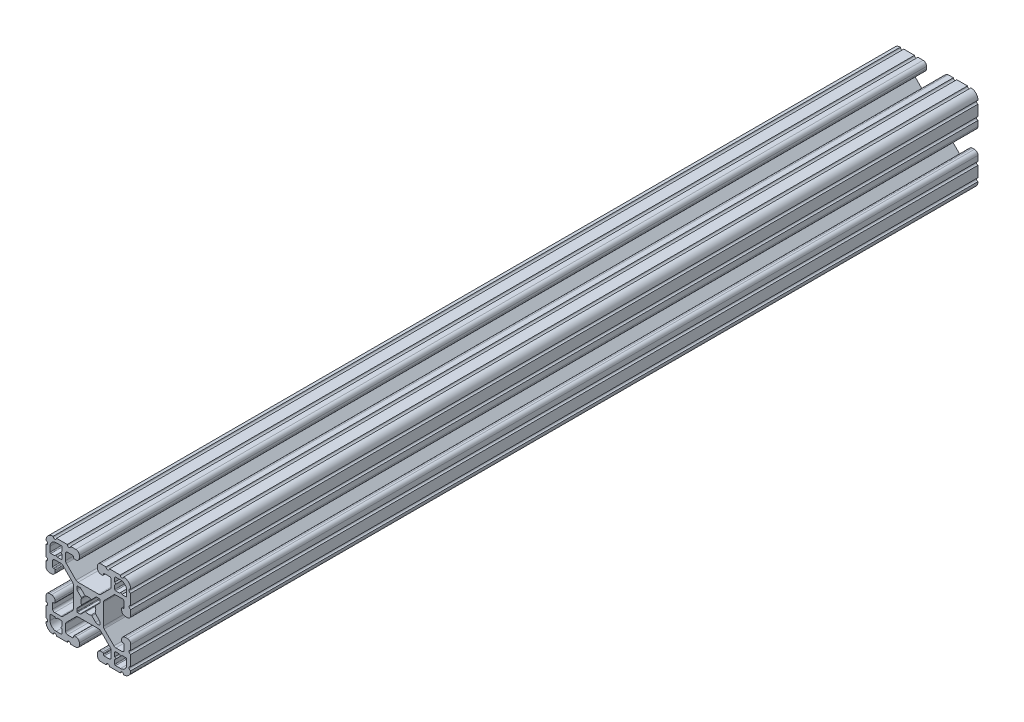
from build123d import *

# Parameters (mm, degrees)
BOSS_EXTRUDE1_DEPTH = 381


with BuildPart() as part:
    # Sketch1 → Boss-Extrude1 (new body)
    with BuildSketch(Plane(origin=(0, 0, -2322.576), x_dir=(-1, 0, 0), z_dir=(0, 0, -1))):
        with BuildLine():
            Line((19.05, -14.325600033), (19.05, -9.4996))
            ThreePointArc((19.05, -9.4996), (18.288, -8.7376), (19.05, -7.9756))
            Line((19.05, -7.9756), (19.05, -5.6388))
            ThreePointArc((19.05, -5.6388), (18.588751759, -4.525248241), (17.4752, -4.064))
            Line((17.4752, -4.064), (16.5608, -4.064))
            ThreePointArc((16.5608, -4.064), (15.447248241, -4.525248241), (14.986, -5.6388))
            Line((14.986, -5.6388), (14.986, -6.350014224))
            ThreePointArc((14.986, -6.350014224), (15.097592316, -6.619421908), (15.367, -6.731014224))
            Line((15.367, -6.731014224), (15.6972, -6.731014224))
            ThreePointArc((15.6972, -6.731014224), (15.966607684, -6.84260654), (16.0782, -7.112014224))
            Line((16.0782, -7.112014224), (16.0782, -9.398014224))
            ThreePointArc((16.0782, -9.398014224), (15.817817928, -10.026632152), (15.1892, -10.287014224))
            Line((15.1892, -10.287014224), (12.375630013, -10.287014224))
            ThreePointArc((12.375630013, -10.287014224), (11.889622054, -10.19034123), (11.477604401, -9.915039836))
            Line((11.477604401, -9.915039836), (7.115699788, -5.553135223))
            ThreePointArc((7.115699788, -5.553135223), (6.840398394, -5.14111757), (6.7437254, -4.655109611))
            Line((6.7437254, -4.655109611), (6.7437254, 4.655109611))
            ThreePointArc((6.7437254, 4.655109611), (6.840398394, 5.14111757), (7.115699788, 5.553135223))
            Line((7.115699788, 5.553135223), (11.477604401, 9.915039836))
            ThreePointArc((11.477604401, 9.915039836), (11.889622054, 10.19034123), (12.375630013, 10.287014224))
            Line((12.375630013, 10.287014224), (15.1892, 10.287014224))
            ThreePointArc((15.1892, 10.287014224), (15.817817928, 10.026632152), (16.0782, 9.398014224))
            Line((16.0782, 9.398014224), (16.0782, 7.112014224))
            ThreePointArc((16.0782, 7.112014224), (15.966607684, 6.84260654), (15.6972, 6.731014224))
            Line((15.6972, 6.731014224), (15.367, 6.731014224))
            ThreePointArc((15.367, 6.731014224), (15.097592316, 6.619421908), (14.986, 6.350014224))
            Line((14.986, 6.350014224), (14.986, 5.6388))
            ThreePointArc((14.986, 5.6388), (15.447248241, 4.525248241), (16.5608, 4.064))
            Line((16.5608, 4.064), (17.4752, 4.064))
            ThreePointArc((17.4752, 4.064), (18.588751759, 4.525248241), (19.05, 5.6388))
            Line((19.05, 5.6388), (19.05, 7.9756))
            ThreePointArc((19.05, 7.9756), (18.288, 8.7376), (19.05, 9.4996))
            Line((19.05, 9.4996), (19.05, 14.325599984))
            ThreePointArc((19.05, 14.325599984), (18.287999986, 15.087549208), (19.049898416, 15.849600009))
            ThreePointArc((19.049898416, 15.849600009), (18.120064036, 18.120064058), (15.849599977, 19.049898414))
            ThreePointArc((15.849599977, 19.049898414), (15.0875492, 18.288000035), (14.325600017, 19.050000016))
            Line((14.325600017, 19.050000016), (9.499600001, 19.050000016))
            ThreePointArc((9.499600001, 19.050000016), (8.737600001, 18.288000016), (7.975600001, 19.050000016))
            Line((7.975600001, 19.050000016), (5.638800016, 19.050000016))
            ThreePointArc((5.638800016, 19.050000016), (4.525248257, 18.588751775), (4.064000016, 17.475200016))
            Line((4.064000016, 17.475200016), (4.064000016, 16.5608))
            ThreePointArc((4.064000016, 16.5608), (4.525248257, 15.447248241), (5.638800016, 14.986))
            Line((5.638800016, 14.986), (6.350014224, 14.986))
            ThreePointArc((6.350014224, 14.986), (6.619421908, 15.097592316), (6.731014224, 15.367))
            Line((6.731014224, 15.367), (6.731014224, 15.6972))
            ThreePointArc((6.731014224, 15.6972), (6.84260654, 15.966607684), (7.112014224, 16.0782))
            Line((7.112014224, 16.0782), (9.398014224, 16.0782))
            ThreePointArc((9.398014224, 16.0782), (10.026632152, 15.817817928), (10.287014224, 15.1892))
            Line((10.287014224, 15.1892), (10.287014224, 12.375630013))
            ThreePointArc((10.287014224, 12.375630013), (10.19034123, 11.889622054), (9.915039836, 11.477604401))
            Line((9.915039836, 11.477604401), (5.553135223, 7.115699788))
            ThreePointArc((5.553135223, 7.115699788), (5.14111757, 6.840398394), (4.655109611, 6.7437254))
            Line((4.655109611, 6.7437254), (-4.655109611, 6.7437254))
            ThreePointArc((-4.655109611, 6.7437254), (-5.14111757, 6.840398394), (-5.553135223, 7.115699788))
            Line((-5.553135223, 7.115699788), (-9.915039836, 11.477604401))
            ThreePointArc((-9.915039836, 11.477604401), (-10.19034123, 11.889622054), (-10.287014224, 12.375630013))
            Line((-10.287014224, 12.375630013), (-10.287014224, 15.1892))
            ThreePointArc((-10.287014224, 15.1892), (-10.026632152, 15.817817928), (-9.398014224, 16.0782))
            Line((-9.398014224, 16.0782), (-7.112014224, 16.0782))
            ThreePointArc((-7.112014224, 16.0782), (-6.84260654, 15.966607684), (-6.731014224, 15.6972))
            Line((-6.731014224, 15.6972), (-6.731014224, 15.367))
            ThreePointArc((-6.731014224, 15.367), (-6.619421908, 15.097592316), (-6.350014224, 14.986))
            Line((-6.350014224, 14.986), (-5.638799984, 14.986))
            ThreePointArc((-5.638799984, 14.986), (-4.525248225, 15.447248241), (-4.063999984, 16.5608))
            Line((-4.063999984, 16.5608), (-4.063999984, 17.475200016))
            ThreePointArc((-4.063999984, 17.475200016), (-4.525248225, 18.588751775), (-5.638799984, 19.050000016))
            Line((-5.638799984, 19.050000016), (-7.975599999, 19.050000016))
            ThreePointArc((-7.975599999, 19.050000016), (-8.737599999, 18.288000016), (-9.499599999, 19.050000016))
            Line((-9.499599999, 19.050000016), (-14.325599999, 19.050000016))
            ThreePointArc((-14.325599999, 19.050000016), (-15.087549199, 18.288000018), (-15.849599993, 19.049898416))
            ThreePointArc((-15.849599993, 19.049898416), (-18.120064042, 18.120064036), (-19.049898398, 15.849599976))
            ThreePointArc((-19.049898398, 15.849599976), (-18.288000019, 15.087549199), (-19.05, 14.325600017))
            Line((-19.05, 14.325600017), (-19.05, 9.4996))
            ThreePointArc((-19.05, 9.4996), (-18.288, 8.7376), (-19.05, 7.9756))
            Line((-19.05, 7.9756), (-19.05, 5.6388))
            ThreePointArc((-19.05, 5.6388), (-18.588751759, 4.525248241), (-17.4752, 4.064))
            Line((-17.4752, 4.064), (-16.5608, 4.064))
            ThreePointArc((-16.5608, 4.064), (-15.447248241, 4.525248241), (-14.986, 5.6388))
            Line((-14.986, 5.6388), (-14.986, 6.350014224))
            ThreePointArc((-14.986, 6.350014224), (-15.097592316, 6.619421908), (-15.367, 6.731014224))
            Line((-15.367, 6.731014224), (-15.6972, 6.731014224))
            ThreePointArc((-15.6972, 6.731014224), (-15.966607684, 6.84260654), (-16.0782, 7.112014224))
            Line((-16.0782, 7.112014224), (-16.0782, 9.398014224))
            ThreePointArc((-16.0782, 9.398014224), (-15.817817928, 10.026632152), (-15.1892, 10.287014224))
            Line((-15.1892, 10.287014224), (-12.375630013, 10.287014224))
            ThreePointArc((-12.375630013, 10.287014224), (-11.889622054, 10.19034123), (-11.477604401, 9.915039836))
            Line((-11.477604401, 9.915039836), (-7.115699788, 5.553135223))
            ThreePointArc((-7.115699788, 5.553135223), (-6.840398394, 5.14111757), (-6.7437254, 4.655109611))
            Line((-6.7437254, 4.655109611), (-6.7437254, -4.655109611))
            ThreePointArc((-6.7437254, -4.655109611), (-6.840398394, -5.14111757), (-7.115699788, -5.553135223))
            Line((-7.115699788, -5.553135223), (-11.477604401, -9.915039836))
            ThreePointArc((-11.477604401, -9.915039836), (-11.889622054, -10.19034123), (-12.375630013, -10.287014224))
            Line((-12.375630013, -10.287014224), (-15.1892, -10.287014224))
            ThreePointArc((-15.1892, -10.287014224), (-15.817817928, -10.026632152), (-16.0782, -9.398014224))
            Line((-16.0782, -9.398014224), (-16.0782, -7.112014224))
            ThreePointArc((-16.0782, -7.112014224), (-15.966607684, -6.84260654), (-15.6972, -6.731014224))
            Line((-15.6972, -6.731014224), (-15.367, -6.731014224))
            ThreePointArc((-15.367, -6.731014224), (-15.097592316, -6.619421908), (-14.986, -6.350014224))
            Line((-14.986, -6.350014224), (-14.986, -5.6388))
            ThreePointArc((-14.986, -5.6388), (-15.447248241, -4.525248241), (-16.5608, -4.064))
            Line((-16.5608, -4.064), (-17.4752, -4.064))
            ThreePointArc((-17.4752, -4.064), (-18.588751759, -4.525248241), (-19.05, -5.6388))
            Line((-19.05, -5.6388), (-19.05, -7.9756))
            ThreePointArc((-19.05, -7.9756), (-18.288, -8.7376), (-19.05, -9.4996))
            Line((-19.05, -9.4996), (-19.05, -14.3256))
            ThreePointArc((-19.05, -14.3256), (-18.288000002, -15.0875492), (-19.0498984, -15.849599993))
            ThreePointArc((-19.0498984, -15.849599993), (-18.120064019, -18.120064043), (-15.84959996, -19.049898399))
            ThreePointArc((-15.84959996, -19.049898399), (-15.087549183, -18.288000019), (-14.325600001, -19.050000001))
            Line((-14.325600001, -19.050000001), (-9.499599984, -19.050000001))
            ThreePointArc((-9.499599984, -19.050000001), (-8.737599984, -18.288000001), (-7.975599984, -19.050000001))
            Line((-7.975599984, -19.050000001), (-5.638799984, -19.050000001))
            ThreePointArc((-5.638799984, -19.050000001), (-4.525248225, -18.58875176), (-4.063999984, -17.475200001))
            Line((-4.063999984, -17.475200001), (-4.063999984, -16.5608))
            ThreePointArc((-4.063999984, -16.5608), (-4.525248225, -15.447248241), (-5.638799984, -14.986))
            Line((-5.638799984, -14.986), (-6.350014224, -14.986))
            ThreePointArc((-6.350014224, -14.986), (-6.619421908, -15.097592316), (-6.731014224, -15.367))
            Line((-6.731014224, -15.367), (-6.731014224, -15.6972))
            ThreePointArc((-6.731014224, -15.6972), (-6.84260654, -15.966607684), (-7.112014224, -16.0782))
            Line((-7.112014224, -16.0782), (-9.398014224, -16.0782))
            ThreePointArc((-9.398014224, -16.0782), (-10.026632152, -15.817817928), (-10.287014224, -15.1892))
            Line((-10.287014224, -15.1892), (-10.287014224, -12.375630013))
            ThreePointArc((-10.287014224, -12.375630013), (-10.19034123, -11.889622054), (-9.915039836, -11.477604401))
            Line((-9.915039836, -11.477604401), (-5.553135223, -7.115699788))
            ThreePointArc((-5.553135223, -7.115699788), (-5.14111757, -6.840398394), (-4.655109611, -6.7437254))
            Line((-4.655109611, -6.7437254), (4.655109611, -6.7437254))
            ThreePointArc((4.655109611, -6.7437254), (5.14111757, -6.840398394), (5.553135223, -7.115699788))
            Line((5.553135223, -7.115699788), (9.915039836, -11.477604401))
            ThreePointArc((9.915039836, -11.477604401), (10.19034123, -11.889622054), (10.287014224, -12.375630013))
            Line((10.287014224, -12.375630013), (10.287014224, -15.1892))
            ThreePointArc((10.287014224, -15.1892), (10.026632152, -15.817817928), (9.398014224, -16.0782))
            Line((9.398014224, -16.0782), (7.112014224, -16.0782))
            ThreePointArc((7.112014224, -16.0782), (6.84260654, -15.966607684), (6.731014224, -15.6972))
            Line((6.731014224, -15.6972), (6.731014224, -15.367))
            ThreePointArc((6.731014224, -15.367), (6.619421908, -15.097592316), (6.350014224, -14.986))
            Line((6.350014224, -14.986), (5.638800016, -14.986))
            ThreePointArc((5.638800016, -14.986), (4.525248257, -15.447248241), (4.064000016, -16.5608))
            Line((4.064000016, -16.5608), (4.064000016, -17.475200001))
            ThreePointArc((4.064000016, -17.475200001), (4.525248257, -18.58875176), (5.638800016, -19.050000001))
            Line((5.638800016, -19.050000001), (7.975600016, -19.050000001))
            ThreePointArc((7.975600016, -19.050000001), (8.737600016, -18.288000001), (9.499600016, -19.050000001))
            Line((9.499600016, -19.050000001), (14.325600016, -19.050000001))
            ThreePointArc((14.325600016, -19.050000001), (15.087549216, -18.288000002), (15.849600009, -19.0498984))
            ThreePointArc((15.849600009, -19.0498984), (18.120064059, -18.12006402), (19.049898415, -15.849599961))
            ThreePointArc((19.049898415, -15.849599961), (18.288000034, -15.087549207), (19.05, -14.325600033))
        make_face()
        with BuildLine():
            Line((17.246614224, 14.452614224), (17.246614224, 12.242814224))
            ThreePointArc((17.246614224, 12.242814224), (17.135021908, 11.97340654), (16.865614224, 11.861814224))
            Line((16.865614224, 11.861814224), (15.092694224, 11.861814224))
            Line((15.092694224, 11.861814224), (14.554214224, 12.400294224))
            Line((14.554214224, 12.400294224), (14.015734224, 11.861814224))
            Line((14.015734224, 11.861814224), (12.242814224, 11.861814224))
            ThreePointArc((12.242814224, 11.861814224), (11.97340654, 11.97340654), (11.861814224, 12.242814224))
            Line((11.861814224, 12.242814224), (11.861814224, 14.015734224))
            Line((11.861814224, 14.015734224), (12.400294224, 14.554214224))
            Line((12.400294224, 14.554214224), (11.861814224, 15.092694224))
            Line((11.861814224, 15.092694224), (11.861814224, 16.865614224))
            ThreePointArc((11.861814224, 16.865614224), (11.97340654, 17.135021908), (12.242814224, 17.246614224))
            Line((12.242814224, 17.246614224), (14.452614224, 17.246614224))
            ThreePointArc((14.452614224, 17.246614224), (16.428270571, 16.428270571), (17.246614224, 14.452614224))
        make_face(mode=Mode.SUBTRACT)
        with BuildLine():
            Line((17.246614224, -12.242814224), (17.246614224, -14.452614224))
            ThreePointArc((17.246614224, -14.452614224), (16.428270571, -16.428270571), (14.452614224, -17.246614224))
            Line((14.452614224, -17.246614224), (12.242814224, -17.246614224))
            ThreePointArc((12.242814224, -17.246614224), (11.97340654, -17.135021908), (11.861814224, -16.865614224))
            Line((11.861814224, -16.865614224), (11.861814224, -15.092694224))
            Line((11.861814224, -15.092694224), (12.400294224, -14.554214224))
            Line((12.400294224, -14.554214224), (11.861814224, -14.015734224))
            Line((11.861814224, -14.015734224), (11.861814224, -12.242814224))
            ThreePointArc((11.861814224, -12.242814224), (11.97340654, -11.97340654), (12.242814224, -11.861814224))
            Line((12.242814224, -11.861814224), (14.015734224, -11.861814224))
            Line((14.015734224, -11.861814224), (14.554214224, -12.400294224))
            Line((14.554214224, -12.400294224), (15.092694224, -11.861814224))
            Line((15.092694224, -11.861814224), (16.865614224, -11.861814224))
            ThreePointArc((16.865614224, -11.861814224), (17.135021908, -11.97340654), (17.246614224, -12.242814224))
        make_face(mode=Mode.SUBTRACT)
        with BuildLine():
            Line((5.1689, -3.920689755), (5.1689, -4.9149))
            ThreePointArc((5.1689, -4.9149), (5.094505122, -5.094505122), (4.9149, -5.1689))
            Line((4.9149, -5.1689), (3.920689755, -5.1689))
            ThreePointArc((3.920689755, -5.1689), (3.580484184, -5.101228904), (3.292071827, -4.908517928))
            Line((3.292071827, -4.908517928), (1.582347442, -3.198793543))
            ThreePointArc((1.582347442, -3.198793543), (1.393016011, -3.095711236), (1.178048687, -3.111879183))
            ThreePointArc((1.178048687, -3.111879183), (0, -3.3274), (-1.178048687, -3.111879183))
            ThreePointArc((-1.178048687, -3.111879183), (-1.393016011, -3.095711236), (-1.582347442, -3.198793543))
            Line((-1.582347442, -3.198793543), (-3.292071827, -4.908517928))
            ThreePointArc((-3.292071827, -4.908517928), (-3.580484184, -5.101228904), (-3.920689755, -5.1689))
            Line((-3.920689755, -5.1689), (-4.9149, -5.1689))
            ThreePointArc((-4.9149, -5.1689), (-5.094505122, -5.094505122), (-5.1689, -4.9149))
            Line((-5.1689, -4.9149), (-5.1689, -3.920689755))
            ThreePointArc((-5.1689, -3.920689755), (-5.101228904, -3.580484184), (-4.908517928, -3.292071827))
            Line((-4.908517928, -3.292071827), (-3.198793543, -1.582347442))
            ThreePointArc((-3.198793543, -1.582347442), (-3.095711236, -1.393016011), (-3.111879183, -1.178048687))
            ThreePointArc((-3.111879183, -1.178048687), (-3.3274, 0), (-3.111879183, 1.178048687))
            ThreePointArc((-3.111879183, 1.178048687), (-3.095711236, 1.393016011), (-3.198793543, 1.582347442))
            Line((-3.198793543, 1.582347442), (-4.908517928, 3.292071827))
            ThreePointArc((-4.908517928, 3.292071827), (-5.101228904, 3.580484184), (-5.1689, 3.920689755))
            Line((-5.1689, 3.920689755), (-5.1689, 4.9149))
            ThreePointArc((-5.1689, 4.9149), (-5.094505122, 5.094505122), (-4.9149, 5.1689))
            Line((-4.9149, 5.1689), (-3.920689755, 5.1689))
            ThreePointArc((-3.920689755, 5.1689), (-3.580484184, 5.101228904), (-3.292071827, 4.908517928))
            Line((-3.292071827, 4.908517928), (-1.582347442, 3.198793543))
            ThreePointArc((-1.582347442, 3.198793543), (-1.393016011, 3.095711236), (-1.178048687, 3.111879183))
            ThreePointArc((-1.178048687, 3.111879183), (0, 3.3274), (1.178048687, 3.111879183))
            ThreePointArc((1.178048687, 3.111879183), (1.393016011, 3.095711236), (1.582347442, 3.198793543))
            Line((1.582347442, 3.198793543), (3.292071827, 4.908517928))
            ThreePointArc((3.292071827, 4.908517928), (3.580484184, 5.101228904), (3.920689755, 5.1689))
            Line((3.920689755, 5.1689), (4.9149, 5.1689))
            ThreePointArc((4.9149, 5.1689), (5.094505122, 5.094505122), (5.1689, 4.9149))
            Line((5.1689, 4.9149), (5.1689, 3.920689755))
            ThreePointArc((5.1689, 3.920689755), (5.101228904, 3.580484184), (4.908517928, 3.292071827))
            Line((4.908517928, 3.292071827), (3.198793543, 1.582347442))
            ThreePointArc((3.198793543, 1.582347442), (3.095711236, 1.393016011), (3.111879183, 1.178048687))
            ThreePointArc((3.111879183, 1.178048687), (3.3274, 0), (3.111879183, -1.178048687))
            ThreePointArc((3.111879183, -1.178048687), (3.095711236, -1.393016011), (3.198793543, -1.582347442))
            Line((3.198793543, -1.582347442), (4.908517928, -3.292071827))
            ThreePointArc((4.908517928, -3.292071827), (5.101228904, -3.580484184), (5.1689, -3.920689755))
        make_face(mode=Mode.SUBTRACT)
        with BuildLine():
            Line((-11.861814224, -12.242814224), (-11.861814224, -14.015734224))
            Line((-11.861814224, -14.015734224), (-12.400294224, -14.554214224))
            Line((-12.400294224, -14.554214224), (-11.861814224, -15.092694224))
            Line((-11.861814224, -15.092694224), (-11.861814224, -16.865614224))
            ThreePointArc((-11.861814224, -16.865614224), (-11.97340654, -17.135021908), (-12.242814224, -17.246614224))
            Line((-12.242814224, -17.246614224), (-14.452614224, -17.246614224))
            ThreePointArc((-14.452614224, -17.246614224), (-16.428270571, -16.428270571), (-17.246614224, -14.452614224))
            Line((-17.246614224, -14.452614224), (-17.246614224, -12.242814224))
            ThreePointArc((-17.246614224, -12.242814224), (-17.135021908, -11.97340654), (-16.865614224, -11.861814224))
            Line((-16.865614224, -11.861814224), (-15.092694224, -11.861814224))
            Line((-15.092694224, -11.861814224), (-14.554214224, -12.400294224))
            Line((-14.554214224, -12.400294224), (-14.015734224, -11.861814224))
            Line((-14.015734224, -11.861814224), (-12.242814224, -11.861814224))
            ThreePointArc((-12.242814224, -11.861814224), (-11.97340654, -11.97340654), (-11.861814224, -12.242814224))
        make_face(mode=Mode.SUBTRACT)
        with BuildLine():
            Line((-11.861814224, 16.865614224), (-11.861814224, 15.092694224))
            Line((-11.861814224, 15.092694224), (-12.400294224, 14.554214224))
            Line((-12.400294224, 14.554214224), (-11.861814224, 14.015734224))
            Line((-11.861814224, 14.015734224), (-11.861814224, 12.242814224))
            ThreePointArc((-11.861814224, 12.242814224), (-11.97340654, 11.97340654), (-12.242814224, 11.861814224))
            Line((-12.242814224, 11.861814224), (-14.015734224, 11.861814224))
            Line((-14.015734224, 11.861814224), (-14.554214224, 12.400294224))
            Line((-14.554214224, 12.400294224), (-15.092694224, 11.861814224))
            Line((-15.092694224, 11.861814224), (-16.865614224, 11.861814224))
            ThreePointArc((-16.865614224, 11.861814224), (-17.135021908, 11.97340654), (-17.246614224, 12.242814224))
            Line((-17.246614224, 12.242814224), (-17.246614224, 14.452614224))
            ThreePointArc((-17.246614224, 14.452614224), (-16.428270571, 16.428270571), (-14.452614224, 17.246614224))
            Line((-14.452614224, 17.246614224), (-12.242814224, 17.246614224))
            ThreePointArc((-12.242814224, 17.246614224), (-11.97340654, 17.135021908), (-11.861814224, 16.865614224))
        make_face(mode=Mode.SUBTRACT)
    extrude(amount=-BOSS_EXTRUDE1_DEPTH)


solid = part.part
